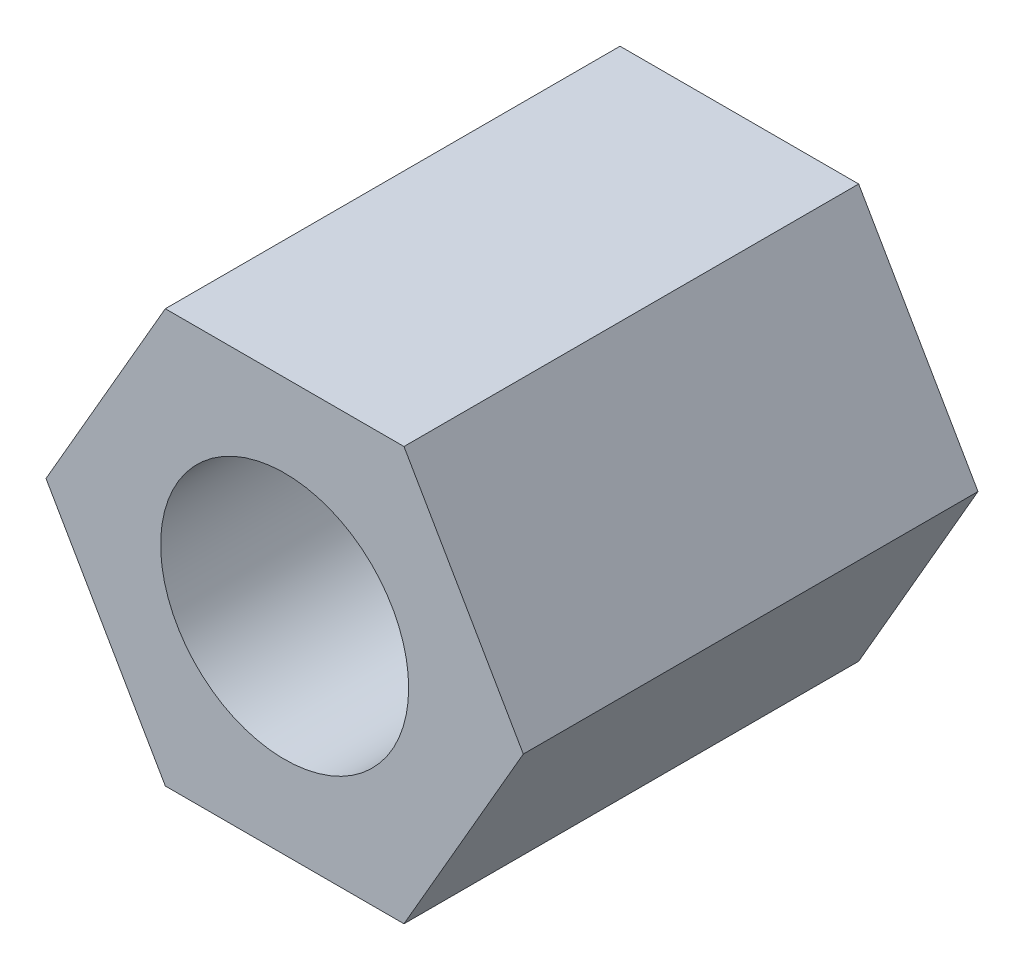
from build123d import *

# Parameters (mm, degrees)
ESTRUSIONE_ESTRUSIONE1_DEPTH = 5.5
SCHIZZO2_R                   = 1.5
TAGLIO_ESTRUSIONE1_DEPTH     = 15


with BuildPart() as part:
    # Schizzo1 → Estrusione-Estrusione1 (new body)
    with BuildSketch(Plane.XY):
        Polygon((1.443375673, 2.5), (-1.443375673, 2.5), (-2.886751346, 0), (-1.443375673, -2.5), (1.443375673, -2.5), (2.886751346, 0), align=None)
    extrude(amount=ESTRUSIONE_ESTRUSIONE1_DEPTH)

    # Schizzo2 → Taglio-Estrusione1 (cut)
    with BuildSketch(Plane.XY.offset(5.5)):
        Circle(SCHIZZO2_R)
    extrude(amount=-TAGLIO_ESTRUSIONE1_DEPTH, mode=Mode.SUBTRACT)


solid = part.part
